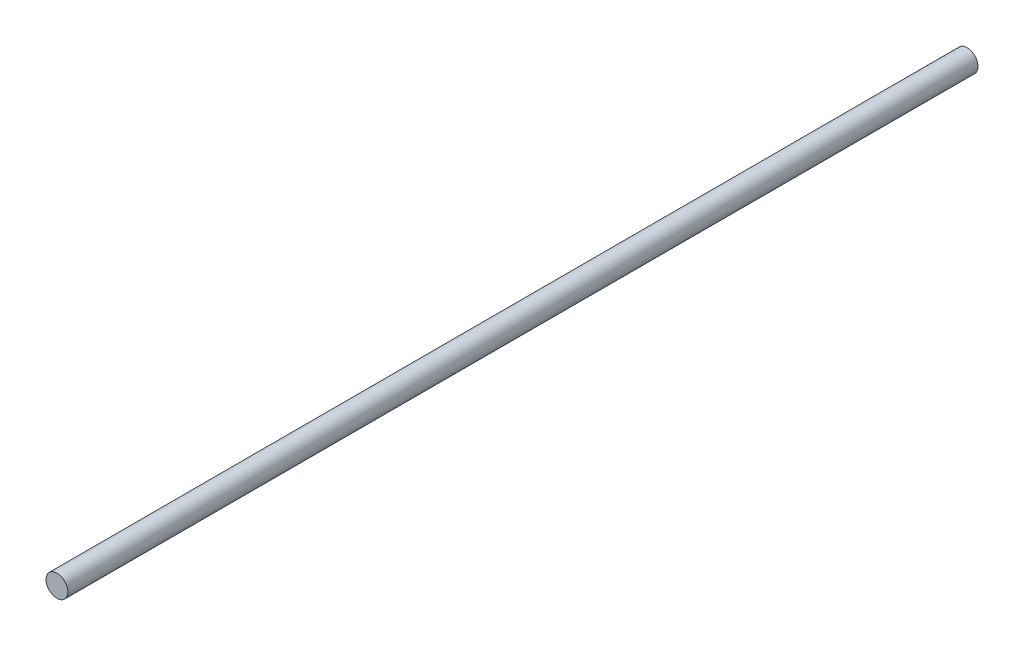
from build123d import *

# Parameters (mm, degrees)
ESBO_O1_R                = 3
RESSALTO_EXTRUS_O1_DEPTH = 250


with BuildPart() as part:
    # Esboço1 → Ressalto-extrusão1 (new body)
    with BuildSketch(Plane.XY):
        Circle(ESBO_O1_R)
    extrude(amount=RESSALTO_EXTRUS_O1_DEPTH)


solid = part.part
